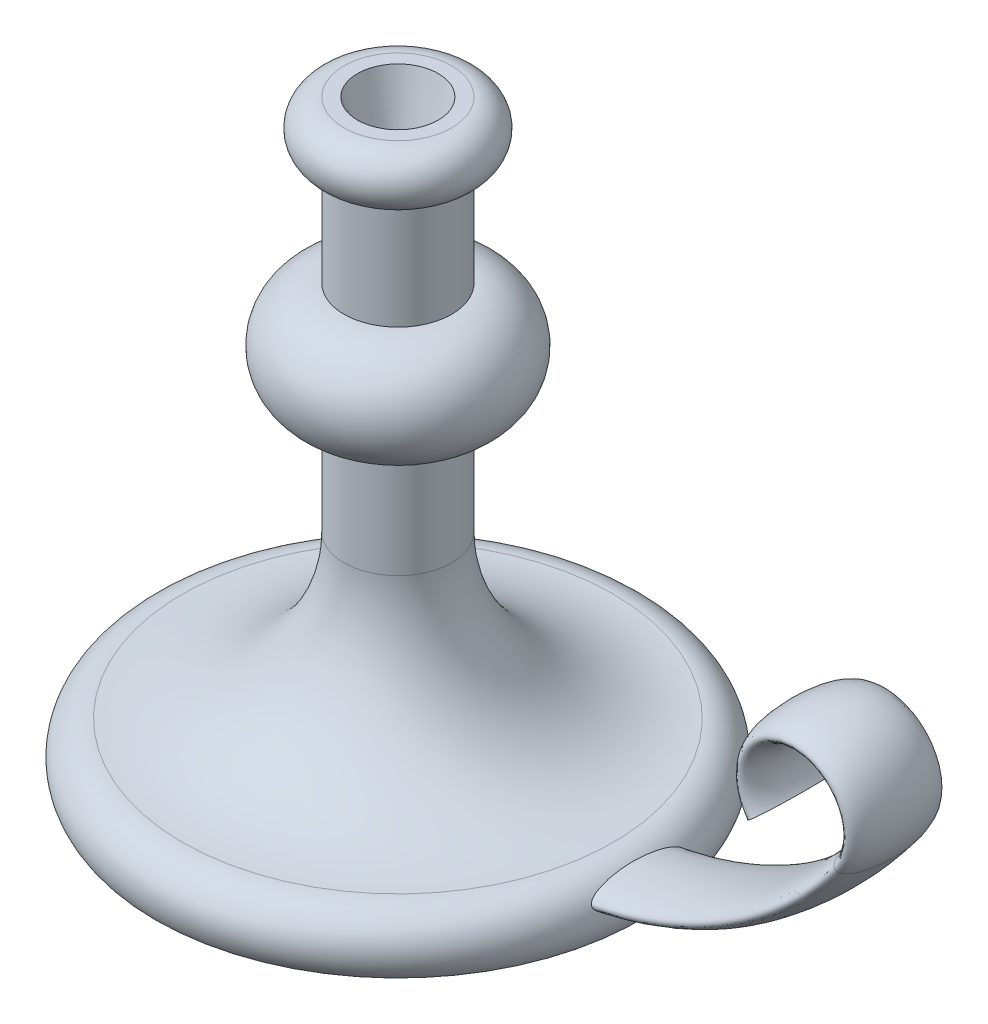
from build123d import *

# Parameters (mm, degrees)
SZKIC13_RX                 = 17.5
SZKIC13_RY                 = 5
SZKIC14_R                  = 15
WYTNIJ_WYCI_GNI_CIE1_DEPTH = 25
WYTNIJ_WYCI_GNI_CIE1_TAPER = 15


with BuildPart() as part:
    # Szkic1 → Obrót1 (revolve)
    with BuildSketch(Plane.XY):
        with BuildLine():
            Line((0, 0), (0, 220))
            Line((0, 220), (20, 220))
            ThreePointArc((20, 220), (30, 210), (20, 200))
            Line((20, 200), (20, 160))
            ThreePointArc((20, 160), (40, 140), (20, 120))
            Line((20, 120), (20, 80))
            ThreePointArc((20, 80), (37.573593129, 37.573593129), (80, 20))
            ThreePointArc((80, 20), (91.180339887, 13.090169944), (90, 0))
            Line((90, 0), (0, 0))
        make_face()
    revolve(axis=Axis((0, 0, 0), (0, 1, 0)))

    # Wyciągnięcie po ścieżce1: sweep along a path in Szkic12
    with BuildLine(Plane.XY) as wyci_gni_cie_po_cie_ce1_path:
        Line((0, 10), (60, 10))
        ThreePointArc((60, 10), (127.082039325, 25.83592135), (180, 70))
        ThreePointArc((180, 70), (164, 102), (148, 70))
    # Szkic13 → Wyciągnięcie po ścieżce1 (sweep)
    with BuildSketch(Plane(origin=(0, 0, 0), x_dir=(0, 0, -1), z_dir=(1, 0, 0))):
        with Locations((0, 10)):
            Ellipse(SZKIC13_RX, SZKIC13_RY)
    sweep(path=wyci_gni_cie_po_cie_ce1_path.line)

    # Szkic14 → Wytnij-wyciągnięcie1 (cut)
    with BuildSketch(Plane(origin=(0, 220, 0), x_dir=(1, 0, 0), z_dir=(0, 1, 0))):
        Circle(SZKIC14_R)
    extrude(amount=-WYTNIJ_WYCI_GNI_CIE1_DEPTH, taper=WYTNIJ_WYCI_GNI_CIE1_TAPER, mode=Mode.SUBTRACT)


solid = part.part
